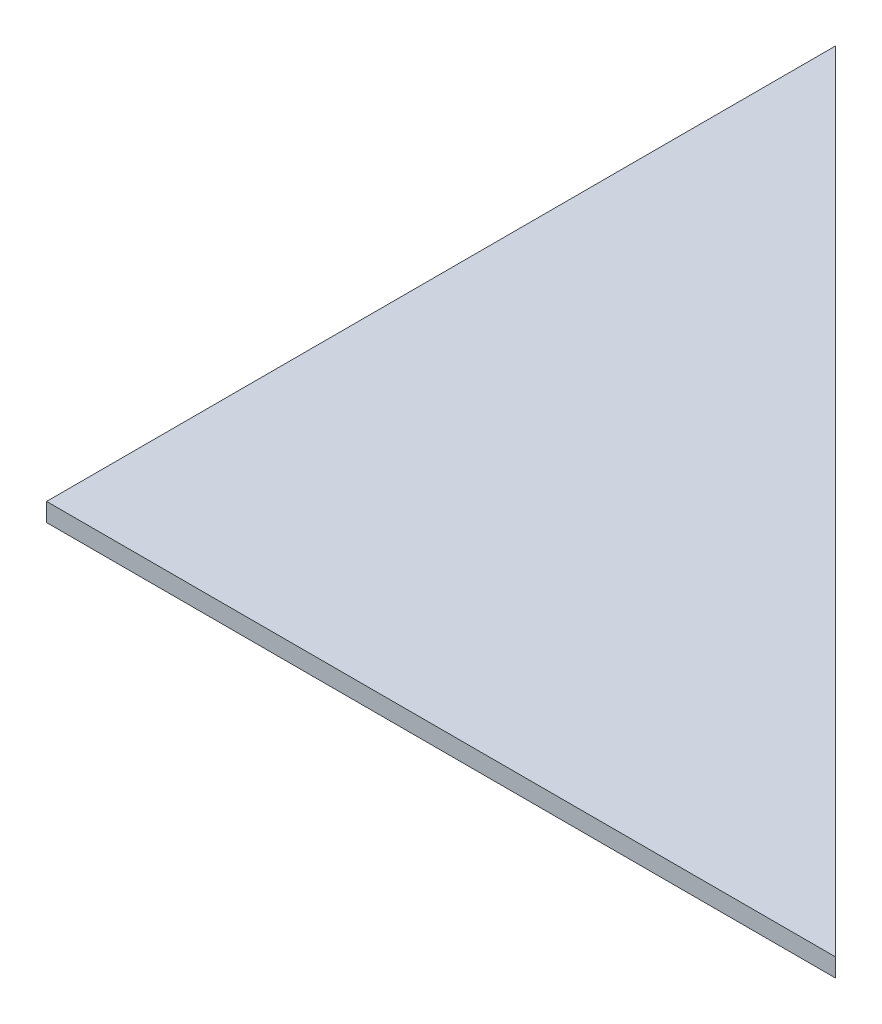
from build123d import *

# Parameters (mm, degrees)
EXTRUDE_1_DEPTH = 5


with BuildPart() as part:
    # 草图1 → 凸台-拉伸1 (new body)
    with BuildSketch(Plane(origin=(0, 0, 0), x_dir=(1, 0, 0), z_dir=(0, 1, 0))):
        Polygon((0, 0), (0, 215), (215, 0), align=None)
    extrude(amount=EXTRUDE_1_DEPTH)


solid = part.part
